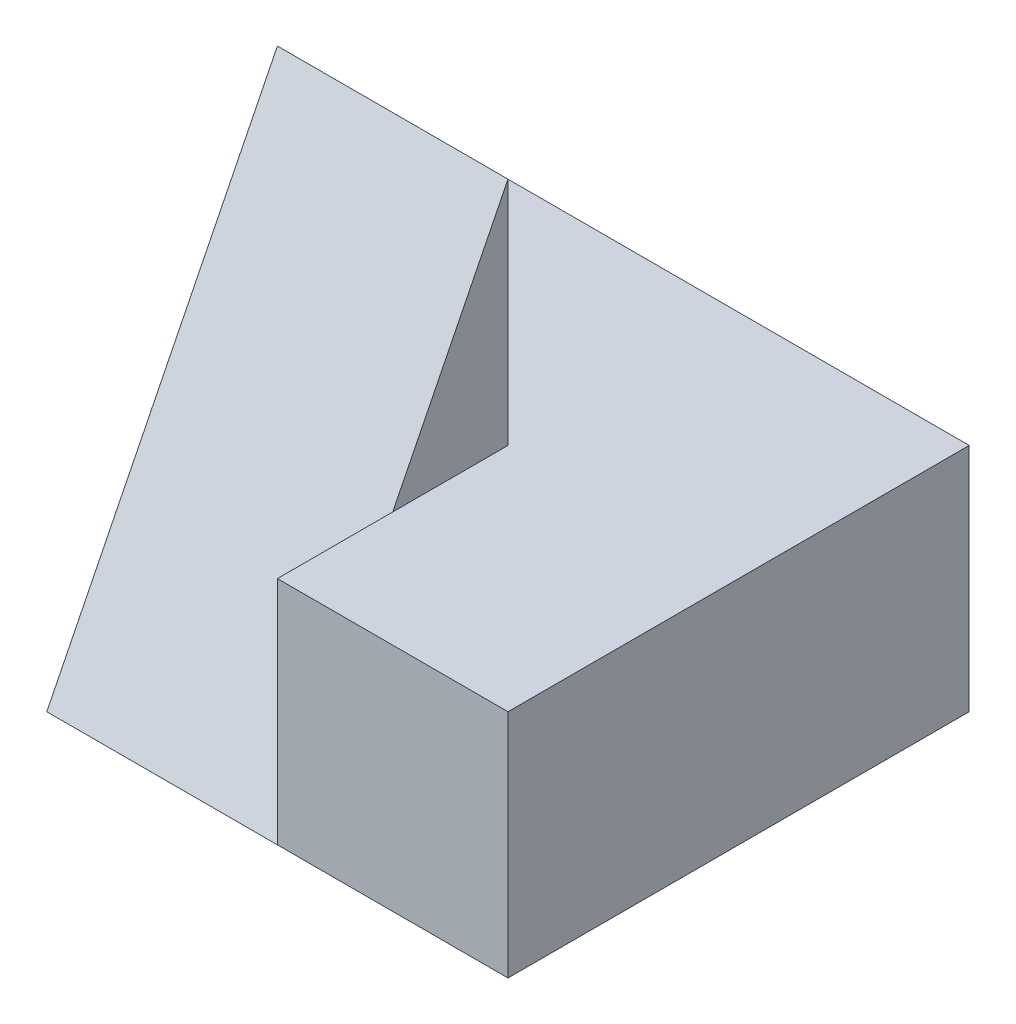
from build123d import *

# Parameters (mm, degrees)
SKETCH1_W           = 4
SKETCH1_H           = 4
BOSS_EXTRUDE1_DEPTH = 4
CUT_EXTRUDE1_DEPTH  = 2
CUT_EXTRUDE2_DEPTH  = 2


with BuildPart() as part:
    # Sketch1 → Boss-Extrude1 (new body)
    with BuildSketch(Plane(origin=(0, 0, 0), x_dir=(1, 0, 0), z_dir=(0, 1, 0))):
        with Locations((2, 2)):
            Rectangle(SKETCH1_W, SKETCH1_H)
    extrude(amount=BOSS_EXTRUDE1_DEPTH)

    # Sketch2 → Cut-Extrude1 (cut)
    with BuildSketch(Plane(origin=(0, 4, 0), x_dir=(1, 0, 0), z_dir=(0, 1, 0))):
        Polygon((0, 4), (0, 2), (2, 2), (2, 0), (4, 0), (4, 4), align=None)
    extrude(amount=-CUT_EXTRUDE1_DEPTH, mode=Mode.SUBTRACT)

    # Sketch3 → Cut-Extrude2 (cut)
    with BuildSketch(Plane.ZY):
        Polygon((0, 0), (-2, 4), (0, 4), align=None)
    extrude(amount=-CUT_EXTRUDE2_DEPTH, mode=Mode.SUBTRACT)


solid = part.part
